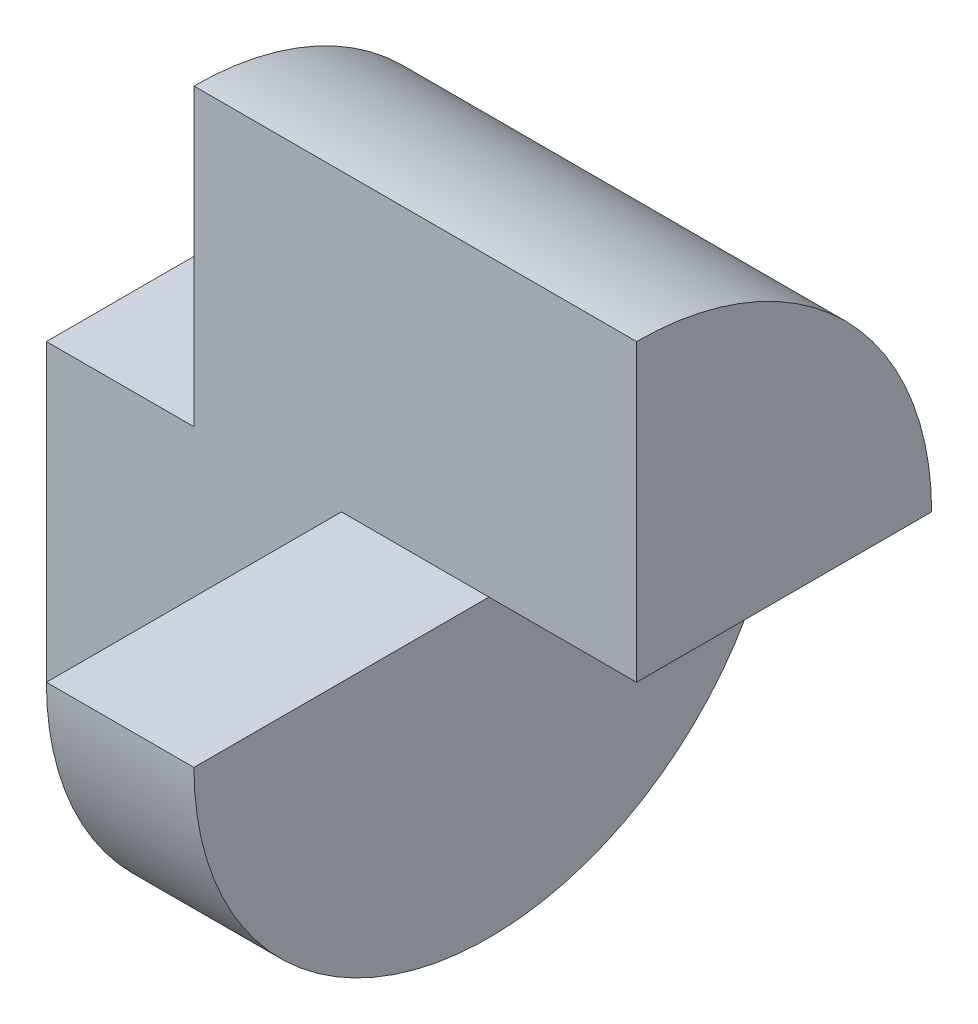
from build123d import *

# Parameters (mm, degrees)
SKETCH1_W           = 40
SKETCH1_H           = 40
BOSS_EXTRUDE1_DEPTH = 40
SKETCH2_W           = 10
SKETCH2_H           = 20
CUT_EXTRUDE1_DEPTH  = 40
SKETCH3_W           = 20
SKETCH3_H           = 20
CUT_EXTRUDE2_DEPTH  = 40
CUT_EXTRUDE3_DEPTH  = 40
CUT_EXTRUDE4_DEPTH  = 40
CUT_EXTRUDE5_DEPTH  = 20


with BuildPart() as part:
    # Sketch1 → Boss-Extrude1 (new body)
    with BuildSketch(Plane.XY):
        with Locations((20, 20)):
            Rectangle(SKETCH1_W, SKETCH1_H)
    extrude(amount=BOSS_EXTRUDE1_DEPTH)

    # Sketch2 → Cut-Extrude1 (cut)
    with BuildSketch(Plane.XY.offset(40)):
        with Locations((5, 30)):
            Rectangle(SKETCH2_W, SKETCH2_H)
        with Locations((35, 10)):
            Rectangle(SKETCH2_W, SKETCH2_H)
    extrude(amount=-CUT_EXTRUDE1_DEPTH, mode=Mode.SUBTRACT)

    # Sketch3 → Cut-Extrude2 (cut)
    with BuildSketch(Plane.ZY.offset(-10)):
        with Locations((30, 30)):
            Rectangle(SKETCH3_W, SKETCH3_H)
    extrude(amount=-CUT_EXTRUDE2_DEPTH, mode=Mode.SUBTRACT)

    # Sketch4 → Cut-Extrude3 (cut)
    with BuildSketch(Plane.ZY.offset(-10)):
        with BuildLine():
            Line((0, 20), (0, 40))
            Line((0, 40), (20, 40))
            ThreePointArc((20, 40), (5.857864376, 34.142135624), (0, 20))
        make_face()
    extrude(amount=-CUT_EXTRUDE3_DEPTH, mode=Mode.SUBTRACT)

    # Sketch5 → Cut-Extrude4 (cut)
    with BuildSketch(Plane.ZY):
        with BuildLine():
            ThreePointArc((20, 0), (5.857864376, 5.857864376), (0, 20))
            Line((0, 20), (0, 0))
            Line((0, 0), (20, 0))
        make_face()
        with BuildLine():
            ThreePointArc((40, 20), (34.142135624, 5.857864376), (20, 0))
            Line((20, 0), (40, 0))
            Line((40, 0), (40, 20))
        make_face()
    extrude(amount=-CUT_EXTRUDE4_DEPTH, mode=Mode.SUBTRACT)

    # Sketch6 → Cut-Extrude5 (cut)
    with BuildSketch(Plane.ZY):
        with BuildLine():
            Line((20, 0), (20, 20))
            Line((20, 20), (40, 20))
            ThreePointArc((40, 20), (34.142135624, 5.857864376), (20, 0))
        make_face()
    extrude(amount=-CUT_EXTRUDE5_DEPTH, mode=Mode.SUBTRACT)


solid = part.part
